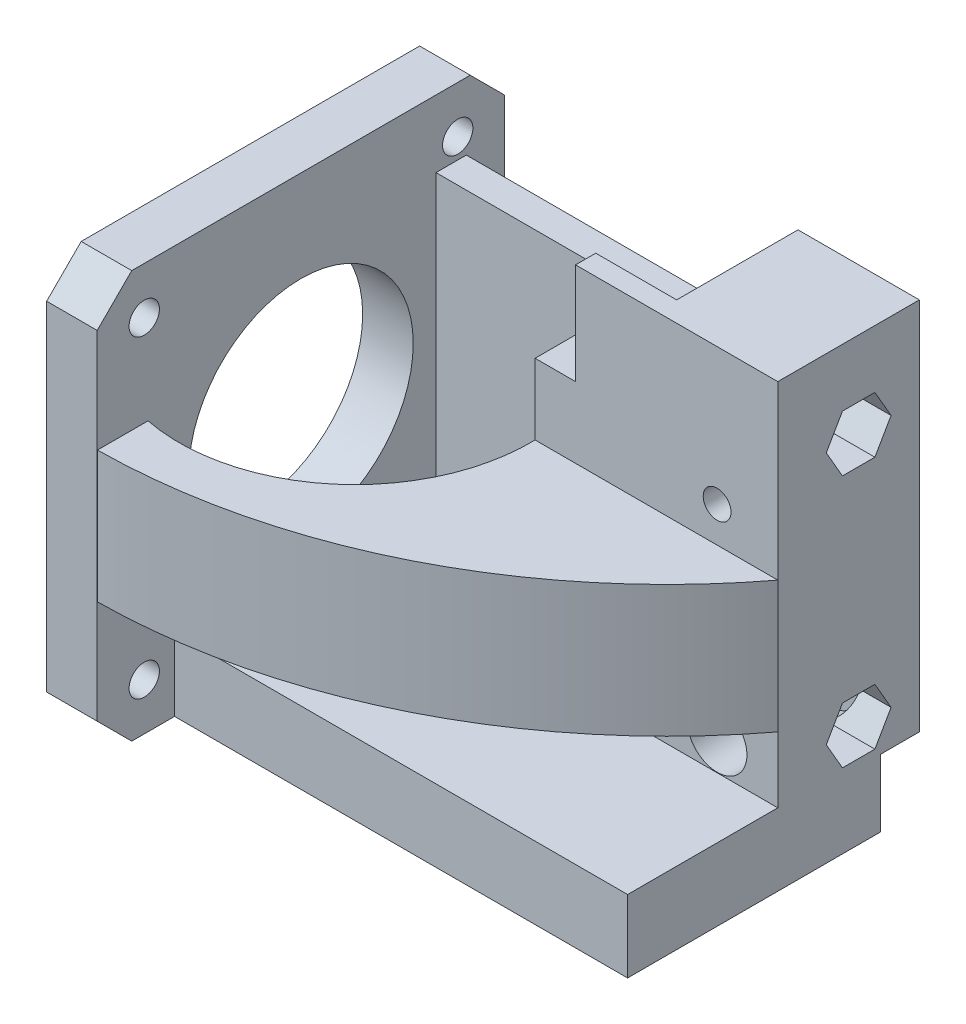
from build123d import *

# Parameters (mm, degrees)
SKETCH1_W             = 12
SKETCH1_H             = 27
SKETCH1_R             = 1.375
BOSS_EXTRUDE1_DEPTH   = 3
SKETCH1_R_2           = 1.35
BOSS_EXTRUDE1_2_DEPTH = 3
SKETCH2_R             = 1.5
SKETCH2_R_2           = 11.1
BOSS_EXTRUDE2_DEPTH   = 5
SKETCH4_W             = 12.8
SKETCH4_H             = 27
BOSS_EXTRUDE3_DEPTH   = 3
SKETCH1_3_W           = 12
SKETCH1_3_H           = 27
SKETCH1_3_R           = 1.35
SKETCH1_3_R_2         = 1.375
BOSS_EXTRUDE4_DEPTH   = 12
SKETCH5_W             = 4
SKETCH5_H             = 27
BOSS_EXTRUDE5_DEPTH   = 9
SKETCH6_W             = 24
SKETCH6_H             = 27
BOSS_EXTRUDE6_DEPTH   = 2
SKETCH1_4_R           = 1.375
SKETCH1_4_R_2         = 1.35
CUT_EXTRUDE3_DEPTH    = 37.501027023
SKETCH10_W            = 8
SKETCH10_H            = 10
BOSS_EXTRUDE7_DEPTH   = 2
BOSS_EXTRUDE8_START   = -14
SKETCH10_4_W          = 12
SKETCH10_4_H          = 10
BOSS_EXTRUDE8_DEPTH   = 14
CUT_EXTRUDE4_START    = -12
SKETCH8_R             = 1.5
CUT_EXTRUDE4_DEPTH    = 24
CUT_EXTRUDE5_REACH    = 26
SKETCH11_R            = 3
BOSS_EXTRUDE9_START   = -7
BOSS_EXTRUDE9_DEPTH   = 13
SKETCH13_W            = 16.851027023
SKETCH13_H            = 6.65
SKETCH13_W_2          = 8.148972977
BOSS_EXTRUDE14_DEPTH  = 24.8
SKETCH13_6_W          = 16.851027023
SKETCH13_6_H          = 6.65
BOSS_EXTRUDE15_DEPTH  = 44.8
BOSS_EXTRUDE16_START  = 32.8
SKETCH13_7_W          = 8.148972977
SKETCH13_7_H          = 6.65
BOSS_EXTRUDE16_DEPTH  = 12
SKETCH16_W            = 44.8
SKETCH16_H            = 0.5
BOSS_EXTRUDE18_DEPTH  = 25.851027
SKETCH14_R            = 1.5
CUT_EXTRUDE8_DEPTH    = 8
CUT_EXTRUDE9_DEPTH    = 11
SKETCH18_R            = 2.95
CUT_EXTRUDE14_DEPTH   = 11.204294


with BuildPart() as part:
    # Sketch1 → Boss-Extrude1 (new body)
    with BuildSketch(Plane.XY):
        with Locations((-10, 0)):
            Rectangle(SKETCH1_W, SKETCH1_H)
        with Locations((-10, -10)):
            Circle(SKETCH1_R, mode=Mode.SUBTRACT)
        with Locations((-10, 10)):
            Circle(SKETCH1_R, mode=Mode.SUBTRACT)
    extrude(amount=BOSS_EXTRUDE1_DEPTH)



with BuildPart() as body_2:
    # Sketch1 → Boss-Extrude1 2 (new body)
    with BuildSketch(Plane.XY):
        with Locations((10, 0)):
            Rectangle(SKETCH1_W, SKETCH1_H)
        with Locations((10, -10)):
            Circle(SKETCH1_R_2, mode=Mode.SUBTRACT)
        with Locations((10, 10)):
            Circle(SKETCH1_R, mode=Mode.SUBTRACT)
    extrude(amount=BOSS_EXTRUDE1_2_DEPTH)

    # Sketch1_3 → Boss-Extrude4 (add)
    with BuildSketch(Plane.XY):
        with Locations((10, 0)):
            Rectangle(SKETCH1_3_W, SKETCH1_3_H)
        with Locations((10, -10)):
            Circle(SKETCH1_3_R, mode=Mode.SUBTRACT)
        with Locations((10, 10)):
            Circle(SKETCH1_3_R_2, mode=Mode.SUBTRACT)
    extrude(amount=BOSS_EXTRUDE4_DEPTH)


with BuildPart() as body_3:
    # Sketch2 → Boss-Extrude2 (new body)
    with BuildSketch(Plane(origin=(-33.8, 0, 0), x_dir=(0, 0, -1), z_dir=(1, 0, 0))):
        Polygon((0.384759414, -20.15), (3.798972977, -16.735786438), (3.798972977, 16.735786438), (0.384759414, 20.15), (-33.086813461, 20.15), (-36.501027023, 16.735786438), (-36.501027023, -16.735786438), (-33.086813461, -20.15), align=None)
        with Locations((-31.851027023, -15.5)):
            Circle(SKETCH2_R, mode=Mode.SUBTRACT)
        with Locations((-0.851027023, -15.5)):
            Circle(SKETCH2_R, mode=Mode.SUBTRACT)
        with Locations((-0.851027023, 15.5)):
            Circle(SKETCH2_R, mode=Mode.SUBTRACT)
        with Locations((-31.851027023, 15.5)):
            Circle(SKETCH2_R, mode=Mode.SUBTRACT)
        with Locations((-16.351027023, 0)):
            Circle(SKETCH2_R_2, mode=Mode.SUBTRACT)
    extrude(amount=BOSS_EXTRUDE2_DEPTH)


with BuildPart() as part_1:
    add(part.part)

    add(body_3.part)  # Boss-Extrude3 merges body 3
    # Sketch4 → Boss-Extrude3 (add)
    with BuildSketch(Plane.XY.offset(3)):
        with Locations((-22.4, 0)):
            Rectangle(SKETCH4_W, SKETCH4_H)
    extrude(amount=-BOSS_EXTRUDE3_DEPTH)

    # Sketch5 → Boss-Extrude5 (add)
    with BuildSketch(Plane.XY.offset(3)):
        with Locations((-6, 0)):
            Rectangle(SKETCH5_W, SKETCH5_H)
    extrude(amount=BOSS_EXTRUDE5_DEPTH)


    add(body_2.part)  # Boss-Extrude6 merges body 2
    # Sketch6 → Boss-Extrude6 (add)
    with BuildSketch(Plane.XY.offset(12)):
        with Locations((4, 0)):
            Rectangle(SKETCH6_W, SKETCH6_H)
    extrude(amount=BOSS_EXTRUDE6_DEPTH)

    # Sketch1_4 → Cut-Extrude3 (cut, through all)
    with BuildSketch(Plane.XY):
        with Locations((10, 10)):
            Circle(SKETCH1_4_R)
        with Locations((10, -10)):
            Circle(SKETCH1_4_R_2)
    extrude(amount=CUT_EXTRUDE3_DEPTH, mode=Mode.SUBTRACT)

    # Sketch10 → Boss-Extrude7 (add)
    with BuildSketch(Plane.XY.offset(14)):
        with Locations((0, 18.5)):
            Rectangle(SKETCH10_W, SKETCH10_H)
    extrude(amount=-BOSS_EXTRUDE7_DEPTH)

    # Sketch10_4 → Boss-Extrude8 (add)
    with BuildSketch(Plane.XY.offset(14).offset(BOSS_EXTRUDE8_START)):
        with Locations((10, 18.5)):
            Rectangle(SKETCH10_4_W, SKETCH10_4_H)
    extrude(amount=BOSS_EXTRUDE8_DEPTH)

    # Sketch8 → Cut-Extrude4 (cut)
    with BuildSketch(Plane(origin=(4, 0, 0), x_dir=(0, 0, -1), z_dir=(1, 0, 0)).offset(CUT_EXTRUDE4_START)):
        with Locations((-6, 15.00007933)):
            Circle(SKETCH8_R)
        with Locations((-6, -9.99992067)):
            Circle(SKETCH8_R)
    extrude(amount=CUT_EXTRUDE4_DEPTH, mode=Mode.SUBTRACT)

    # Sketch11 → Cut-Extrude5 (cut, up to next)
    with BuildSketch(Plane.ZY.offset(8), mode=Mode.PRIVATE) as cut_extrude5_sk1:
        with Locations((6, -9.99992067)):
            Circle(SKETCH11_R)
    cut_extrude5_tool1 = extrude(cut_extrude5_sk1.sketch, amount=-CUT_EXTRUDE5_REACH, mode=Mode.PRIVATE) & part_1.part
    add(cut_extrude5_tool1.solids().sort_by_distance((-8, -9.999921, 6))[0], mode=Mode.SUBTRACT)
    # Sketch11 → Cut-Extrude5 (cut, up to next)
    with BuildSketch(Plane.ZY.offset(8), mode=Mode.PRIVATE) as cut_extrude5_sk2:
        with Locations((6, 15.00007933)):
            Circle(SKETCH11_R)
    cut_extrude5_tool2 = extrude(cut_extrude5_sk2.sketch, amount=-CUT_EXTRUDE5_REACH, mode=Mode.PRIVATE) & part_1.part
    add(cut_extrude5_tool2.solids().sort_by_distance((-8, 15.000079, 6))[0], mode=Mode.SUBTRACT)

    # Sketch12 → Boss-Extrude9 (add)
    with BuildSketch(Plane.XZ.offset(13.5).offset(BOSS_EXTRUDE9_START)):
        with BuildLine():
            Line((-28.776802955, 36.501027023), (-28.776802955, 31.501027023))
            ThreePointArc((-28.776802955, 31.501027023), (-14.183037571, 27.743021501), (-8, 14))
            Line((-8, 14), (16, 14))
            ThreePointArc((16, 14), (-3.776982896, 30.447208539), (-28.776802955, 36.501027023))
        make_face()
    extrude(amount=-BOSS_EXTRUDE9_DEPTH)



with BuildPart() as body_2_2:
    # Sketch13 → Boss-Extrude14 (new body)
    with BuildSketch(Plane(origin=(-28.8, 0, 0), x_dir=(0, 0, -1), z_dir=(1, 0, 0))):
        with Locations((-20.425513512, -16.825)):
            Rectangle(SKETCH13_W, SKETCH13_H)
        with Locations((-7.925513512, -16.825)):
            Rectangle(SKETCH13_W_2, SKETCH13_H)
    extrude(amount=BOSS_EXTRUDE14_DEPTH)


with BuildPart() as part_2:
    add(part_1.part)

    add(body_2_2.part)  # Boss-Extrude15 merges body 2 2
    # Sketch13_6 → Boss-Extrude15 (add)
    with BuildSketch(Plane(origin=(-28.8, 0, 0), x_dir=(0, 0, -1), z_dir=(1, 0, 0))):
        with Locations((-20.425513512, -16.825)):
            Rectangle(SKETCH13_6_W, SKETCH13_6_H)
    extrude(amount=BOSS_EXTRUDE15_DEPTH)

    # Sketch13_7 → Boss-Extrude16 (add)
    with BuildSketch(Plane(origin=(-28.8, 0, 0), x_dir=(0, 0, -1), z_dir=(1, 0, 0)).offset(BOSS_EXTRUDE16_START)):
        with Locations((-7.925513512, -16.825)):
            Rectangle(SKETCH13_7_W, SKETCH13_7_H)
    extrude(amount=BOSS_EXTRUDE16_DEPTH)

    # Sketch16 → Boss-Extrude18 (add)
    with BuildSketch(Plane.XY.offset(3)):
        with Locations((-6.4, -13.25)):
            Rectangle(SKETCH16_W, SKETCH16_H)
    extrude(amount=BOSS_EXTRUDE18_DEPTH)

    # Sketch14 → Cut-Extrude8 (cut)
    with BuildSketch(Plane(origin=(-28.8, 0, 0), x_dir=(0, 0, -1), z_dir=(1, 0, 0))):
        with BuildLine():
            ThreePointArc((-3.087095001, -13.5), (-3.6535441, -14.429533731), (-3.851027023, -15.5))
            ThreePointArc((-3.851027023, -15.5), (-0.851027023, -18.5), (2.148972977, -15.5))
            ThreePointArc((2.148972977, -15.5), (1.951490054, -14.429533731), (1.385040954, -13.5))
            Line((1.385040954, -13.5), (0, -13.5))
            Line((0, -13.5), (-3, -13.5))
            Line((-3, -13.5), (-3.087095001, -13.5))
        make_face()
        with Locations((-0.851027023, -15.5)):
            Circle(SKETCH14_R, mode=Mode.SUBTRACT)
        with BuildLine():
            Line((0, -13.5), (1.385040954, -13.5))
            ThreePointArc((1.385040954, -13.5), (0.753565225, -12.965185664), (0, -12.623239147))
            Line((0, -12.623239147), (0, -13.5))
        make_face()
        with BuildLine():
            Line((-3, -13.40669755), (-3, -13.5))
            Line((-3, -13.5), (0, -13.5))
            Line((0, -13.5), (0, -12.623239147))
            ThreePointArc((0, -12.623239147), (-1.609062439, -12.59734909), (-3, -13.40669755))
        make_face()
    extrude(amount=CUT_EXTRUDE8_DEPTH, mode=Mode.SUBTRACT)

    # Sketch17 → Cut-Extrude9 (cut)
    with BuildSketch(Plane(origin=(16, 0, 0), x_dir=(0, 0, -1), z_dir=(1, 0, 0))):
        Polygon((-9.204293994, -9.99992067), (-7.602146997, -7.22492067), (-4.397853003, -7.22492067), (-2.795706006, -9.99992067), (-4.397853003, -12.77492067), (-7.602146997, -12.77492067), align=None)
        Polygon((-9.204293994, 15.00007933), (-7.602146997, 17.77507933), (-4.397853003, 17.77507933), (-2.795706006, 15.00007933), (-4.397853003, 12.22507933), (-7.602146997, 12.22507933), align=None)
    extrude(amount=-CUT_EXTRUDE9_DEPTH, mode=Mode.SUBTRACT)

    # Sketch18 → Cut-Extrude14 (cut)
    with BuildSketch(Plane.XY.offset(14)):
        with Locations((10, -10)):
            Circle(SKETCH18_R)
    extrude(amount=-CUT_EXTRUDE14_DEPTH, mode=Mode.SUBTRACT)


solid = part_2.part
